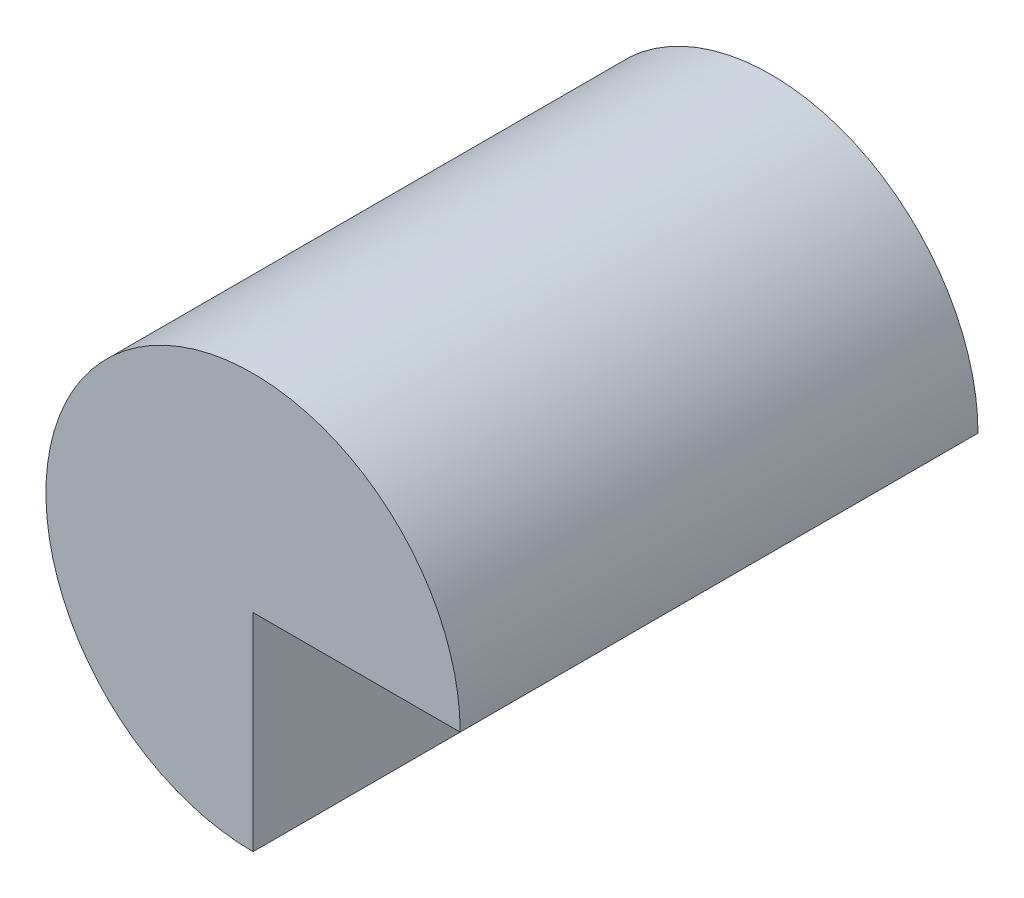
from build123d import *

# Parameters (mm, degrees)
BOSS_EXTRUDE1_DEPTH = 25


with BuildPart() as part:
    # Sketch1 → Boss-Extrude1 (new body)
    with BuildSketch(Plane.XY):
        with BuildLine():
            Line((-10, -10), (-10, 0))
            Line((-10, 0), (0, 0))
            ThreePointArc((0, 0), (-17.071067812, 7.071067812), (-10, -10))
        make_face()
    extrude(amount=BOSS_EXTRUDE1_DEPTH)


solid = part.part
